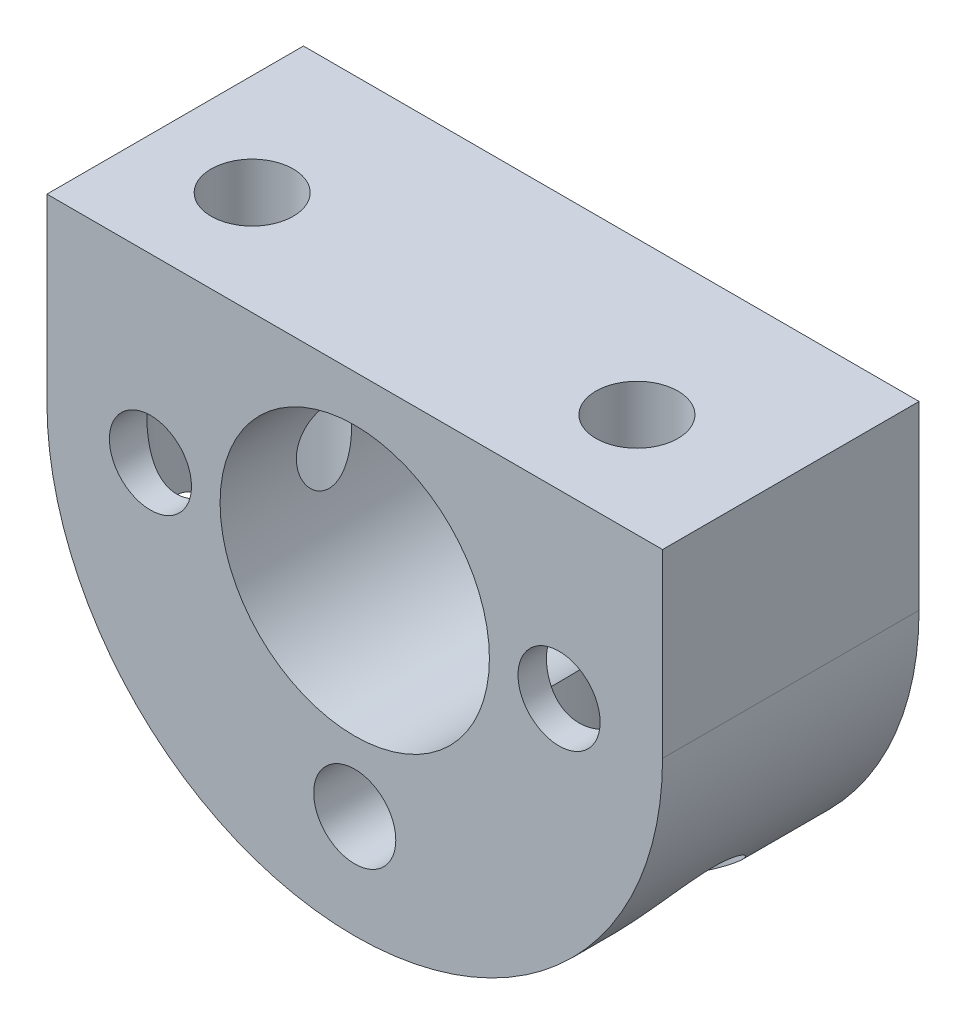
from build123d import *

# Parameters (mm, degrees)
RESSALTO_EXTRUS_O1_DEPTH                = 10
ESBO_O2_R                               = 5.25
CORTE_EXTRUS_O1_DEPTH                   = 16
CORTE_EXTRUS_O1_DEPTH_BACK              = 31.8
CBORE_FOR_M5_HEX_HEAD_BOLT1_D           = 3.2
CBORE_FOR_M5_HEX_HEAD_BOLT1_CBORE_D     = 6
CBORE_FOR_M5_HEX_HEAD_BOLT1_CBORE_DEPTH = 16.5
M3_CLEARANCE_HOLE5_D                    = 3.2


with BuildPart() as part:
    # Esboço1 → Ressalto-extrusão1 (new body)
    with BuildSketch(Plane.XY):
        with BuildLine():
            Line((115.646593224, -302.7659332), (115.646593224, -295.7159332))
            Line((115.646593224, -295.7159332), (91.646593224, -295.7159332))
            Line((91.646593224, -295.7159332), (91.646593224, -302.7659332))
            ThreePointArc((91.646593224, -302.7659332), (103.646593224, -314.7659332), (115.646593224, -302.7659332))
        make_face()
    extrude(amount=RESSALTO_EXTRUS_O1_DEPTH)

    # Esboço2 → Corte-extrusão1 (cut, two sides)
    with BuildSketch(Plane.XY.offset(10)) as corte_extrus_o1_sk:
        with Locations((103.646593224, -302.7659332)):
            Circle(ESBO_O2_R)
    extrude(amount=CORTE_EXTRUS_O1_DEPTH, mode=Mode.SUBTRACT)
    extrude(corte_extrus_o1_sk.sketch, amount=-CORTE_EXTRUS_O1_DEPTH_BACK, mode=Mode.SUBTRACT)

    # CBORE for M5 Hex Head Bolt1 (through all)
    with Locations(Plane(origin=(0, -314.7159332, 0), x_dir=(-1, 0, 0), z_dir=(0, -1, 0))):
        with Locations((-95.596593224, -5.949346208), (-110.596593224, -5.949346208)):
            CounterBoreHole(CBORE_FOR_M5_HEX_HEAD_BOLT1_D / 2, CBORE_FOR_M5_HEX_HEAD_BOLT1_CBORE_D / 2, CBORE_FOR_M5_HEX_HEAD_BOLT1_CBORE_DEPTH)

    # M3 Clearance Hole5 (through all)
    with Locations(Plane.XY.offset(10)):
        with Locations((95.681870132, -302.765933199), (103.646593224, -310.730656291), (111.611316315, -302.765933199)):
            Hole(M3_CLEARANCE_HOLE5_D / 2)


solid = part.part
